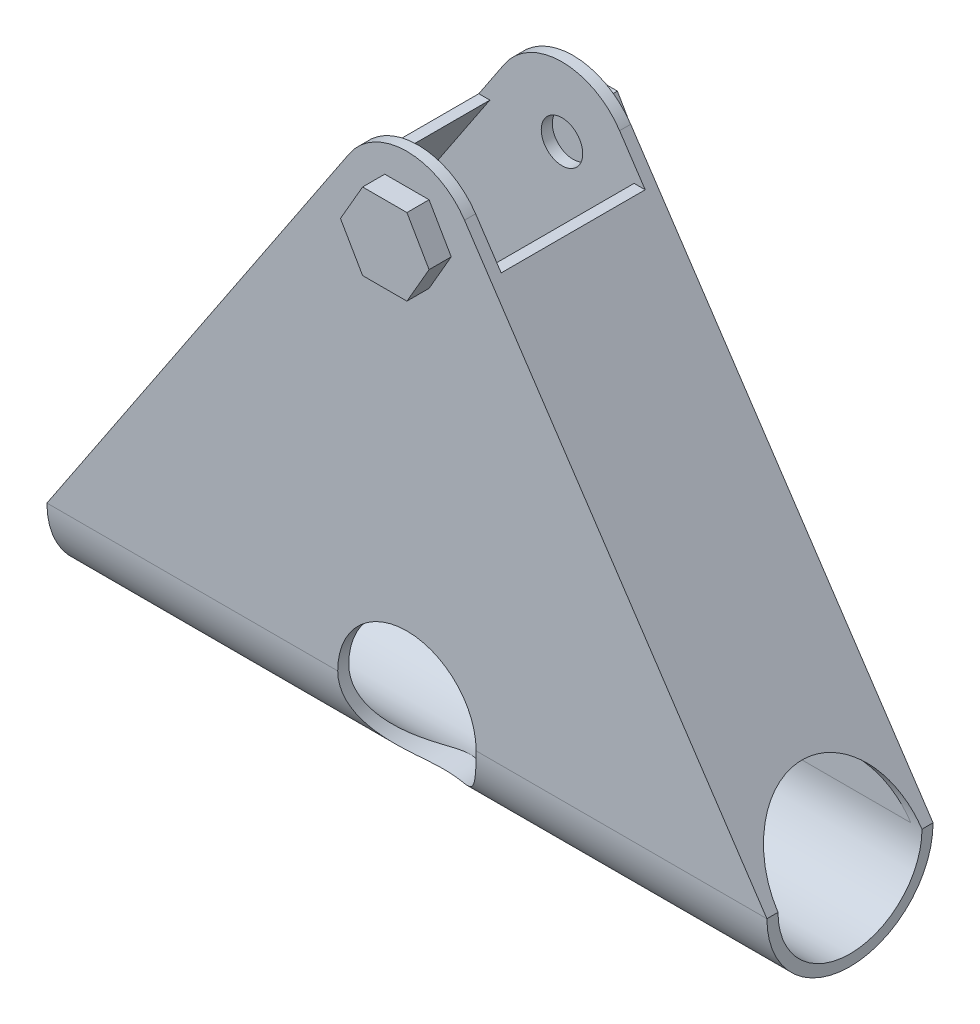
from build123d import *

# Parameters (mm, degrees)
SKETCH1_R                = 3.75
BOSS_EXTRUDE1_DEPTH      = 2
BOSS_EXTRUDE2_DEPTH      = 65
BOSS_EXTRUDE2_DEPTH_BACK = 65
SKETCH4_R                = 3.75
BOSS_EXTRUDE3_DEPTH      = 2
CUT_EXTRUDE1_DEPTH       = 115.494541355
CUT_EXTRUDE1_DEPTH_BACK  = 115.494541355
SKETCH5_R                = 12.5
BOSS_EXTRUDE4_DEPTH      = 26
CUT_EXTRUDE2_DEPTH       = 115.494541514
CUT_EXTRUDE2_DEPTH_BACK  = 115.494541514
SKETCH7_R                = 13
BOSS_EXTRUDE5_DEPTH      = 4
BOSS_EXTRUDE6_DEPTH      = 4


with BuildPart() as part:
    # Sketch1 → Boss-Extrude1 (new body)
    with BuildSketch(Plane.XY):
        with BuildLine():
            Line((-10.40198382, 6.931719311), (-65, -75))
            Line((-65, -75), (65, -75))
            Line((65, -75), (10.40198382, 6.931719311))
            ThreePointArc((10.40198382, 6.931719311), (0, 12.5), (-10.40198382, 6.931719311))
        make_face()
        Circle(SKETCH1_R, mode=Mode.SUBTRACT)
    extrude(amount=BOSS_EXTRUDE1_DEPTH)

    # Sketch2 → Boss-Extrude2 (add, two sides: drawn at the far end of the back side and taken through both)
    with BuildSketch(Plane(origin=(0, 0, 0), x_dir=(0, 0, -1), z_dir=(1, 0, 0)).offset(-BOSS_EXTRUDE2_DEPTH_BACK)):
        with BuildLine():
            Line((0, -75), (-2, -75))
            ThreePointArc((-2, -75), (13, -90), (28, -75))
            Line((28, -75), (26, -75))
            ThreePointArc((26, -75), (13, -88), (0, -75))
        make_face()
    extrude(amount=BOSS_EXTRUDE2_DEPTH + BOSS_EXTRUDE2_DEPTH_BACK)

    # Sketch4 → Boss-Extrude3 (add)
    with BuildSketch(Plane(origin=(0, 0, -28), x_dir=(-1, 0, 0), z_dir=(0, 0, -1))):
        with BuildLine():
            Line((65, -75), (10.40198382, 6.931719311))
            ThreePointArc((10.40198382, 6.931719311), (0, 12.5), (-10.40198382, 6.931719311))
            Line((-10.40198382, 6.931719311), (-65, -75))
            Line((-65, -75), (65, -75))
        make_face()
        Circle(SKETCH4_R, mode=Mode.SUBTRACT)
    extrude(amount=-BOSS_EXTRUDE3_DEPTH)

    # Sketch5 → Cut-Extrude1 (cut, two sides: drawn at the far end of the back side and taken through both)
    with BuildSketch(Plane.XY.offset(-CUT_EXTRUDE1_DEPTH_BACK)):
        with Locations((0, -75)):
            Circle(SKETCH5_R)
    extrude(amount=CUT_EXTRUDE1_DEPTH + CUT_EXTRUDE1_DEPTH_BACK, mode=Mode.SUBTRACT)

    # Sketch6 → Boss-Extrude4 (add)
    with BuildSketch(Plane.XY):
        Polygon((15.021173144, 0), (13.021173144, 0), (63, -75), (65, -75), align=None)
        Polygon((-13.021173144, 0), (-15.021173144, 0), (-65, -75), (-63, -75), align=None)
    extrude(amount=-BOSS_EXTRUDE4_DEPTH)

    # Sketch7 → Cut-Extrude2 (cut, two sides: drawn at the far end of the back side and taken through both)
    with BuildSketch(Plane(origin=(0, 0, 0), x_dir=(0, 0, -1), z_dir=(1, 0, 0)).offset(-CUT_EXTRUDE2_DEPTH_BACK)):
        with Locations((13, -75)):
            Circle(SKETCH7_R)
    extrude(amount=CUT_EXTRUDE2_DEPTH + CUT_EXTRUDE2_DEPTH_BACK, mode=Mode.SUBTRACT)

    # Sketch8 → Boss-Extrude5 (add)
    with BuildSketch(Plane(origin=(0, 0, -28), x_dir=(-1, 0, 0), z_dir=(0, 0, -1))):
        Polygon((8, 0), (4, 6.92820323), (-4, 6.92820323), (-8, 0), (-4, -6.92820323), (4, -6.92820323), align=None)
    extrude(amount=BOSS_EXTRUDE5_DEPTH)

    # Sketch9 → Boss-Extrude6 (add)
    with BuildSketch(Plane.XY.offset(2)):
        Polygon((8, 0), (4, 6.92820323), (-4, 6.92820323), (-8, 0), (-4, -6.92820323), (4, -6.92820323), align=None)
    extrude(amount=BOSS_EXTRUDE6_DEPTH)


solid = part.part
